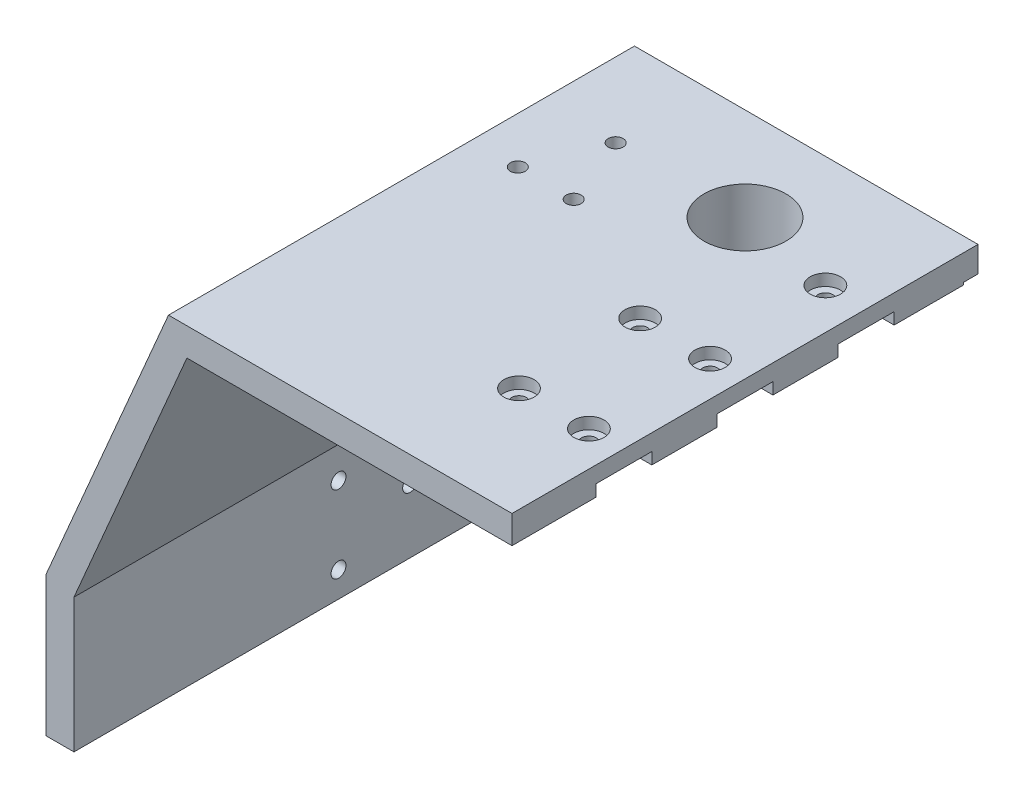
from build123d import *

# Parameters (mm, degrees)
SALIENTE_EXTRUIR1_DEPTH = 100
CORTAR_EXTRUIR1_REACH   = 170.346
CROQUIS3_R              = 8.8
CORTAR_EXTRUIR2_REACH   = 226.945
CROQUIS4_R              = 8.8
CORTAR_EXTRUIR3_DEPTH   = 0.5
CORTAR_EXTRUIR4_REACH   = 241.691
CROQUIS6_R              = 1.6
CROQUIS7_R              = 3.25
CORTAR_EXTRUIR5_DEPTH   = 2.5
CROQUIS8_W              = 75
CROQUIS8_H              = 12
CROQUIS8_W_2            = 35
CORTAR_EXTRUIR6_DEPTH   = 2.5
CORTAR_EXTRUIR7_REACH   = 168.473
CROQUIS9_R              = 1.6
CROQUIS10_R             = 3.25
CORTAR_EXTRUIR8_DEPTH   = 2.5
CROQUIS11_R             = 10.3
CROQUIS11_R_2           = 8.8
SALIENTE_EXTRUIR2_DEPTH = 10
SALIENTE_EXTRUIR3_REACH = 201.802
CROQUIS12_R             = 10.3
CROQUIS12_R_2           = 8.8
CORTAR_EXTRUIR9_REACH   = 167.168
CROQUIS13_R             = 1.6
CROQUIS14_W             = 100
CROQUIS14_H             = 100
CORTAR_EXTRUIR10_DEPTH  = 169.345575526


with BuildPart() as part:
    # Croquis1 → Saliente-Extruir1 (new body)
    with BuildSketch(Plane.XY):
        Polygon((-100, 25), (-100, -5), (-94, -5), (-94, 23.768453788), (-69.761533754, 80.324875029), (69.761533754, 80.324875029), (94, 23.768453788), (94, -5), (100, -5), (100, 25), (73.717910702, 86.324875029), (-73.717910702, 86.324875029), align=None)
    extrude(amount=SALIENTE_EXTRUIR1_DEPTH)

    # Croquis3 → Cortar-Extruir1 (cut, up to next)
    with BuildSketch(Plane(origin=(0, 86.324875029, 0), x_dir=(1, 0, 0), z_dir=(0, 1, 0)), mode=Mode.PRIVATE) as cortar_extruir1_sk1:
        with Locations(Location((-30, -20, 0), (0, 0, 270))):
            Circle(CROQUIS3_R)
    cortar_extruir1_tool1 = extrude(cortar_extruir1_sk1.sketch, amount=-CORTAR_EXTRUIR1_REACH, mode=Mode.PRIVATE) & part.part
    # Croquis3 → Cortar-Extruir1 (cut, up to next)
    with BuildSketch(Plane(origin=(0, 86.324875029, 0), x_dir=(1, 0, 0), z_dir=(0, 1, 0)), mode=Mode.PRIVATE) as cortar_extruir1_sk2:
        with Locations(Location((30, -20, 0), (0, 0, 270))):
            Circle(CROQUIS3_R)
    cortar_extruir1_tool2 = extrude(cortar_extruir1_sk2.sketch, amount=-CORTAR_EXTRUIR1_REACH, mode=Mode.PRIVATE) & part.part
    add(cortar_extruir1_tool1.solids().sort_by_distance((-30, 86.324875, 20))[0], mode=Mode.SUBTRACT)
    add(cortar_extruir1_tool2.solids().sort_by_distance((30, 86.324875, 20))[0], mode=Mode.SUBTRACT)

    # Cortar-Extruir2: up to this plane
    cortar_extruir2_end = Plane(origin=(-94, 23.768453788, 100), z_dir=(-0.9191450300180581, 0.3939192985791672, 0))
    # Croquis4 → Cortar-Extruir2 (cut, up to the surface)
    with BuildSketch(Plane(origin=(-87.479517168, 68.836107355, 0), x_dir=(0, 0, -1), z_dir=(-0.7858721058939679, 0.6183890629512945, 0)), mode=Mode.PRIVATE) as cortar_extruir2_sk1:
        with Locations(Location((-20, 9.96907102, 0), (0, 0, 270))):
            Circle(CROQUIS4_R)
    cortar_extruir2_tool1 = split(extrude(cortar_extruir2_sk1.sketch, amount=-CORTAR_EXTRUIR2_REACH, mode=Mode.PRIVATE), bisect_by=cortar_extruir2_end, keep=Keep.BOTH, mode=Mode.PRIVATE)
    cortar_extruir2 = cortar_extruir2_tool1.solids().sort_by_distance((-93.644282, 61.001693, 20))[0]
    add(cortar_extruir2, mode=Mode.SUBTRACT)

    # Simetría1: Cortar-Extruir2 across plane
    add(cortar_extruir2.mirror(Plane(origin=(0, 0, 0), x_dir=(0, 0, 1), z_dir=(1, 0, 0))), mode=Mode.SUBTRACT)

    # Croquis5 → Cortar-Extruir3 (cut)
    with BuildSketch(Plane.XZ.offset(-80.324875029)):
        with BuildLine():
            Line((14.875, 0), (15.175, 0))
            Line((15.175, 0), (15.175, 2.3))
            Line((15.175, 2.3), (3.784177586, 2.3))
            ThreePointArc((3.784177586, 2.3), (0, 3.1), (-3.784177586, 2.3))
            Line((-3.784177586, 2.3), (-15.175, 2.3))
            Line((-15.175, 2.3), (-15.175, 0))
            Line((-15.175, 0), (-14.875, 0))
            Line((-14.875, 0), (-14.875, 2))
            Line((-14.875, 2), (-3.720215048, 2))
            ThreePointArc((-3.720215048, 2), (0, 2.8), (3.720215048, 2))
            Line((3.720215048, 2), (14.875, 2))
            Line((14.875, 2), (14.875, 0))
        make_face()
        with BuildLine():
            Line((3.261901286, 0), (14.875, 0))
            Line((14.875, 0), (14.875, 2))
            Line((14.875, 2), (3.720215048, 2))
            ThreePointArc((3.720215048, 2), (0, 2.8), (-3.720215048, 2))
            Line((-3.720215048, 2), (-14.875, 2))
            Line((-14.875, 2), (-14.875, 0))
            Line((-14.875, 0), (-3.261901286, 0))
            ThreePointArc((-3.261901286, 0), (0, 0.8), (3.261901286, 0))
        make_face()
        with BuildLine():
            Line((-3.261901286, 0), (3.261901286, 0))
            ThreePointArc((3.261901286, 0), (0, 0.8), (-3.261901286, 0))
        make_face()
    extrude(amount=-CORTAR_EXTRUIR3_DEPTH, mode=Mode.SUBTRACT)

    # Croquis6 → Cortar-Extruir4 (cut, up to next)
    with BuildSketch(Plane.ZY.offset(100), mode=Mode.PRIVATE) as cortar_extruir4_sk1:
        with Locations(Location((43.227046774, 0.497681725, 0), (0, 0, 270))):
            Circle(CROQUIS6_R)
    cortar_extruir4_tool1 = extrude(cortar_extruir4_sk1.sketch, amount=-CORTAR_EXTRUIR4_REACH, mode=Mode.PRIVATE) & part.part
    # Croquis6 → Cortar-Extruir4 (cut, up to next)
    with BuildSketch(Plane.ZY.offset(100), mode=Mode.PRIVATE) as cortar_extruir4_sk2:
        with Locations(Location((27.863523387, 8.768453788, 0), (0, 0, 270))):
            Circle(CROQUIS6_R)
    cortar_extruir4_tool2 = extrude(cortar_extruir4_sk2.sketch, amount=-CORTAR_EXTRUIR4_REACH, mode=Mode.PRIVATE) & part.part
    # Croquis6 → Cortar-Extruir4 (cut, up to next)
    with BuildSketch(Plane.ZY.offset(100), mode=Mode.PRIVATE) as cortar_extruir4_sk3:
        with Locations(Location((43.227046774, 17.039225851, 0), (0, 0, 270))):
            Circle(CROQUIS6_R)
    cortar_extruir4_tool3 = extrude(cortar_extruir4_sk3.sketch, amount=-CORTAR_EXTRUIR4_REACH, mode=Mode.PRIVATE) & part.part
    cortar_extruir4_1 = cortar_extruir4_tool1.solids().sort_by_distance((-100, 0.497682, 43.227047))[0]
    add(cortar_extruir4_1, mode=Mode.SUBTRACT)
    cortar_extruir4_2 = cortar_extruir4_tool2.solids().sort_by_distance((-100, 8.768454, 27.863523))[0]
    add(cortar_extruir4_2, mode=Mode.SUBTRACT)
    cortar_extruir4_3 = cortar_extruir4_tool3.solids().sort_by_distance((-100, 17.039226, 43.227047))[0]
    add(cortar_extruir4_3, mode=Mode.SUBTRACT)
    cortar_extruir4 = cortar_extruir4_1 + cortar_extruir4_2 + cortar_extruir4_3  # Cortar-Extruir4 as one shape, for the pattern or mirror that repeats it

    # Croquis7 → Cortar-Extruir5 (cut)
    with BuildSketch(Plane.ZY.offset(100)):
        with Locations(Location((27.863523387, 8.768453788, 0), (0, 0, 270))):
            Circle(CROQUIS7_R)
        with Locations(Location((43.227046774, 0.497681725, 0), (0, 0, 270))):
            Circle(CROQUIS7_R)
        with Locations(Location((43.227046774, 17.039225851, 0), (0, 0, 270))):
            Circle(CROQUIS7_R)
    cortar_extruir5 = extrude(amount=-CORTAR_EXTRUIR5_DEPTH, mode=Mode.SUBTRACT)

    # Simetría2: Cortar-Extruir4, Cortar-Extruir5 across plane
    add(cortar_extruir4.mirror(Plane(origin=(0, 0, 0), x_dir=(0, 0, 1), z_dir=(1, 0, 0))), mode=Mode.SUBTRACT)
    add(cortar_extruir5.mirror(Plane(origin=(0, 0, 0), x_dir=(0, 0, 1), z_dir=(1, 0, 0))), mode=Mode.SUBTRACT)

    # Croquis8 → Cortar-Extruir6 (cut)
    with BuildSketch(Plane.XZ.offset(-80.324875029)):
        with Locations((0, 76)):
            Rectangle(CROQUIS8_W, CROQUIS8_H)
        with Locations((0, 50)):
            Rectangle(CROQUIS8_W, CROQUIS8_H)
        with Locations((0, 24)):
            Rectangle(CROQUIS8_W_2, CROQUIS8_H)
    extrude(amount=-CORTAR_EXTRUIR6_DEPTH, mode=Mode.SUBTRACT)

    # Croquis9 → Cortar-Extruir7 (cut, up to next)
    with BuildSketch(Plane.XZ.offset(-82.824875029), mode=Mode.PRIVATE) as cortar_extruir7_sk1:
        with Locations(Location((-22.5, 76, 0), (0, 0, 270))):
            Circle(CROQUIS9_R)
    cortar_extruir7_tool1 = extrude(cortar_extruir7_sk1.sketch, amount=-CORTAR_EXTRUIR7_REACH, mode=Mode.PRIVATE) & part.part
    # Croquis9 → Cortar-Extruir7 (cut, up to next)
    with BuildSketch(Plane.XZ.offset(-82.824875029), mode=Mode.PRIVATE) as cortar_extruir7_sk2:
        with Locations(Location((-7.5, 76, 0), (0, 0, 270))):
            Circle(CROQUIS9_R)
    cortar_extruir7_tool2 = extrude(cortar_extruir7_sk2.sketch, amount=-CORTAR_EXTRUIR7_REACH, mode=Mode.PRIVATE) & part.part
    # Croquis9 → Cortar-Extruir7 (cut, up to next)
    with BuildSketch(Plane.XZ.offset(-82.824875029), mode=Mode.PRIVATE) as cortar_extruir7_sk3:
        with Locations(Location((7.5, 76, 0), (0, 0, 270))):
            Circle(CROQUIS9_R)
    cortar_extruir7_tool3 = extrude(cortar_extruir7_sk3.sketch, amount=-CORTAR_EXTRUIR7_REACH, mode=Mode.PRIVATE) & part.part
    # Croquis9 → Cortar-Extruir7 (cut, up to next)
    with BuildSketch(Plane.XZ.offset(-82.824875029), mode=Mode.PRIVATE) as cortar_extruir7_sk4:
        with Locations(Location((22.5, 76, 0), (0, 0, 270))):
            Circle(CROQUIS9_R)
    cortar_extruir7_tool4 = extrude(cortar_extruir7_sk4.sketch, amount=-CORTAR_EXTRUIR7_REACH, mode=Mode.PRIVATE) & part.part
    # Croquis9 → Cortar-Extruir7 (cut, up to next)
    with BuildSketch(Plane.XZ.offset(-82.824875029), mode=Mode.PRIVATE) as cortar_extruir7_sk5:
        with Locations(Location((-22.5, 50, 0), (0, 0, 270))):
            Circle(CROQUIS9_R)
    cortar_extruir7_tool5 = extrude(cortar_extruir7_sk5.sketch, amount=-CORTAR_EXTRUIR7_REACH, mode=Mode.PRIVATE) & part.part
    # Croquis9 → Cortar-Extruir7 (cut, up to next)
    with BuildSketch(Plane.XZ.offset(-82.824875029), mode=Mode.PRIVATE) as cortar_extruir7_sk6:
        with Locations(Location((-7.5, 50, 0), (0, 0, 270))):
            Circle(CROQUIS9_R)
    cortar_extruir7_tool6 = extrude(cortar_extruir7_sk6.sketch, amount=-CORTAR_EXTRUIR7_REACH, mode=Mode.PRIVATE) & part.part
    # Croquis9 → Cortar-Extruir7 (cut, up to next)
    with BuildSketch(Plane.XZ.offset(-82.824875029), mode=Mode.PRIVATE) as cortar_extruir7_sk7:
        with Locations(Location((7.5, 50, 0), (0, 0, 270))):
            Circle(CROQUIS9_R)
    cortar_extruir7_tool7 = extrude(cortar_extruir7_sk7.sketch, amount=-CORTAR_EXTRUIR7_REACH, mode=Mode.PRIVATE) & part.part
    # Croquis9 → Cortar-Extruir7 (cut, up to next)
    with BuildSketch(Plane.XZ.offset(-82.824875029), mode=Mode.PRIVATE) as cortar_extruir7_sk8:
        with Locations(Location((22.5, 50, 0), (0, 0, 270))):
            Circle(CROQUIS9_R)
    cortar_extruir7_tool8 = extrude(cortar_extruir7_sk8.sketch, amount=-CORTAR_EXTRUIR7_REACH, mode=Mode.PRIVATE) & part.part
    # Croquis9 → Cortar-Extruir7 (cut, up to next)
    with BuildSketch(Plane.XZ.offset(-82.824875029), mode=Mode.PRIVATE) as cortar_extruir7_sk9:
        with Locations(Location((-8.75, 24, 0), (0, 0, 270))):
            Circle(CROQUIS9_R)
    cortar_extruir7_tool9 = extrude(cortar_extruir7_sk9.sketch, amount=-CORTAR_EXTRUIR7_REACH, mode=Mode.PRIVATE) & part.part
    # Croquis9 → Cortar-Extruir7 (cut, up to next)
    with BuildSketch(Plane.XZ.offset(-82.824875029), mode=Mode.PRIVATE) as cortar_extruir7_sk10:
        with Locations(Location((8.75, 24, 0), (0, 0, 270))):
            Circle(CROQUIS9_R)
    cortar_extruir7_tool10 = extrude(cortar_extruir7_sk10.sketch, amount=-CORTAR_EXTRUIR7_REACH, mode=Mode.PRIVATE) & part.part
    add(cortar_extruir7_tool1.solids().sort_by_distance((-22.5, 82.824875, 76))[0], mode=Mode.SUBTRACT)
    add(cortar_extruir7_tool2.solids().sort_by_distance((-7.5, 82.824875, 76))[0], mode=Mode.SUBTRACT)
    add(cortar_extruir7_tool3.solids().sort_by_distance((7.5, 82.824875, 76))[0], mode=Mode.SUBTRACT)
    add(cortar_extruir7_tool4.solids().sort_by_distance((22.5, 82.824875, 76))[0], mode=Mode.SUBTRACT)
    add(cortar_extruir7_tool5.solids().sort_by_distance((-22.5, 82.824875, 50))[0], mode=Mode.SUBTRACT)
    add(cortar_extruir7_tool6.solids().sort_by_distance((-7.5, 82.824875, 50))[0], mode=Mode.SUBTRACT)
    add(cortar_extruir7_tool7.solids().sort_by_distance((7.5, 82.824875, 50))[0], mode=Mode.SUBTRACT)
    add(cortar_extruir7_tool8.solids().sort_by_distance((22.5, 82.824875, 50))[0], mode=Mode.SUBTRACT)
    add(cortar_extruir7_tool9.solids().sort_by_distance((-8.75, 82.824875, 24))[0], mode=Mode.SUBTRACT)
    add(cortar_extruir7_tool10.solids().sort_by_distance((8.75, 82.824875, 24))[0], mode=Mode.SUBTRACT)

    # Croquis10 → Cortar-Extruir8 (cut)
    with BuildSketch(Plane(origin=(0, 86.324875029, 0), x_dir=(1, 0, 0), z_dir=(0, 1, 0))):
        with Locations(Location((-22.5, -50, 0), (0, 0, 270))):
            Circle(CROQUIS10_R)
        with Locations(Location((-7.5, -50, 0), (0, 0, 270))):
            Circle(CROQUIS10_R)
        with Locations(Location((7.5, -50, 0), (0, 0, 270))):
            Circle(CROQUIS10_R)
        with Locations(Location((22.5, -50, 0), (0, 0, 270))):
            Circle(CROQUIS10_R)
        with Locations(Location((8.75, -24, 0), (0, 0, 270))):
            Circle(CROQUIS10_R)
        with Locations(Location((-8.75, -24, 0), (0, 0, 270))):
            Circle(CROQUIS10_R)
        with Locations(Location((22.5, -76, 0), (0, 0, 270))):
            Circle(CROQUIS10_R)
        with Locations(Location((7.5, -76, 0), (0, 0, 270))):
            Circle(CROQUIS10_R)
        with Locations(Location((-7.5, -76, 0), (0, 0, 270))):
            Circle(CROQUIS10_R)
        with Locations(Location((-22.5, -76, 0), (0, 0, 270))):
            Circle(CROQUIS10_R)
    extrude(amount=-CORTAR_EXTRUIR8_DEPTH, mode=Mode.SUBTRACT)

    # Croquis11 → Saliente-Extruir2 (add)
    with BuildSketch(Plane.XZ.offset(-80.324875029)):
        with Locations(Location((-30, 20, 0), (0, 0, 90))):
            Circle(CROQUIS11_R)
        with Locations(Location((-30, 20, 0), (0, 0, 90))):
            Circle(CROQUIS11_R_2, mode=Mode.SUBTRACT)
        with Locations(Location((30, 20, 0), (0, 0, 90))):
            Circle(CROQUIS11_R)
        with Locations(Location((30, 20, 0), (0, 0, 90))):
            Circle(CROQUIS11_R_2, mode=Mode.SUBTRACT)
    extrude(amount=SALIENTE_EXTRUIR2_DEPTH)

    # Saliente-Extruir3: up to this plane
    saliente_extruir3_end = Plane(origin=(-94, 23.768453788, 100), z_dir=(-0.9191450300180581, 0.3939192985791672, 0))
    # Croquis12 → Saliente-Extruir3 (add, up to the surface)
    with BuildSketch(Plane(origin=(-63.903353991, 50.284435467, 0), x_dir=(0, 0, -1), z_dir=(-0.7858721058939679, 0.6183890629512945, 0)), mode=Mode.PRIVATE) as saliente_extruir3_sk1:
        with Locations(Location((-20, 9.96907102, 0), (0, 0, 90))):
            Circle(CROQUIS12_R)
        with Locations(Location((-20, 9.96907102, 0), (0, 0, 90))):
            Circle(CROQUIS12_R_2, mode=Mode.SUBTRACT)
    saliente_extruir3_tool1 = split(extrude(saliente_extruir3_sk1.sketch, amount=SALIENTE_EXTRUIR3_REACH, mode=Mode.PRIVATE), bisect_by=saliente_extruir3_end, keep=Keep.BOTH, mode=Mode.PRIVATE)
    add(saliente_extruir3_tool1.solids().sort_by_distance((-63.878865, 50.315557, 20))[0])

    # Croquis13 → Cortar-Extruir9 (cut, up to next)
    with BuildSketch(Plane.XZ.offset(-80.324875029), mode=Mode.PRIVATE) as cortar_extruir9_sk1:
        with Locations(Location((57.761533754, 20, 0), (0, 0, 270))):
            Circle(CROQUIS13_R)
    cortar_extruir9_tool1 = extrude(cortar_extruir9_sk1.sketch, amount=-CORTAR_EXTRUIR9_REACH, mode=Mode.PRIVATE) & part.part
    # Croquis13 → Cortar-Extruir9 (cut, up to next)
    with BuildSketch(Plane.XZ.offset(-80.324875029), mode=Mode.PRIVATE) as cortar_extruir9_sk2:
        with Locations(Location((51.761533754, 35, 0), (0, 0, 270))):
            Circle(CROQUIS13_R)
    cortar_extruir9_tool2 = extrude(cortar_extruir9_sk2.sketch, amount=-CORTAR_EXTRUIR9_REACH, mode=Mode.PRIVATE) & part.part
    # Croquis13 → Cortar-Extruir9 (cut, up to next)
    with BuildSketch(Plane.XZ.offset(-80.324875029), mode=Mode.PRIVATE) as cortar_extruir9_sk3:
        with Locations(Location((63.761533754, 35, 0), (0, 0, 270))):
            Circle(CROQUIS13_R)
    cortar_extruir9_tool3 = extrude(cortar_extruir9_sk3.sketch, amount=-CORTAR_EXTRUIR9_REACH, mode=Mode.PRIVATE) & part.part
    # Croquis13 → Cortar-Extruir9 (cut, up to next)
    with BuildSketch(Plane.XZ.offset(-80.324875029), mode=Mode.PRIVATE) as cortar_extruir9_sk4:
        with Locations(Location((-57.761533754, 20, 0), (0, 0, 270))):
            Circle(CROQUIS13_R)
    cortar_extruir9_tool4 = extrude(cortar_extruir9_sk4.sketch, amount=-CORTAR_EXTRUIR9_REACH, mode=Mode.PRIVATE) & part.part
    # Croquis13 → Cortar-Extruir9 (cut, up to next)
    with BuildSketch(Plane.XZ.offset(-80.324875029), mode=Mode.PRIVATE) as cortar_extruir9_sk5:
        with Locations(Location((-63.761533754, 35, 0), (0, 0, 270))):
            Circle(CROQUIS13_R)
    cortar_extruir9_tool5 = extrude(cortar_extruir9_sk5.sketch, amount=-CORTAR_EXTRUIR9_REACH, mode=Mode.PRIVATE) & part.part
    # Croquis13 → Cortar-Extruir9 (cut, up to next)
    with BuildSketch(Plane.XZ.offset(-80.324875029), mode=Mode.PRIVATE) as cortar_extruir9_sk6:
        with Locations(Location((-51.761533754, 35, 0), (0, 0, 270))):
            Circle(CROQUIS13_R)
    cortar_extruir9_tool6 = extrude(cortar_extruir9_sk6.sketch, amount=-CORTAR_EXTRUIR9_REACH, mode=Mode.PRIVATE) & part.part
    add(cortar_extruir9_tool1.solids().sort_by_distance((57.761534, 80.324875, 20))[0], mode=Mode.SUBTRACT)
    add(cortar_extruir9_tool2.solids().sort_by_distance((51.761534, 80.324875, 35))[0], mode=Mode.SUBTRACT)
    add(cortar_extruir9_tool3.solids().sort_by_distance((63.761534, 80.324875, 35))[0], mode=Mode.SUBTRACT)
    add(cortar_extruir9_tool4.solids().sort_by_distance((-57.761534, 80.324875, 20))[0], mode=Mode.SUBTRACT)
    add(cortar_extruir9_tool5.solids().sort_by_distance((-63.761534, 80.324875, 35))[0], mode=Mode.SUBTRACT)
    add(cortar_extruir9_tool6.solids().sort_by_distance((-51.761534, 80.324875, 35))[0], mode=Mode.SUBTRACT)

    # Croquis14 → Cortar-Extruir10 (cut, through all)
    with BuildSketch(Plane(origin=(0, 86.324875029, 0), x_dir=(1, 0, 0), z_dir=(0, 1, 0))):
        with Locations((50, -50)):
            Rectangle(CROQUIS14_W, CROQUIS14_H)
    extrude(amount=-CORTAR_EXTRUIR10_DEPTH, mode=Mode.SUBTRACT)


solid = part.part
